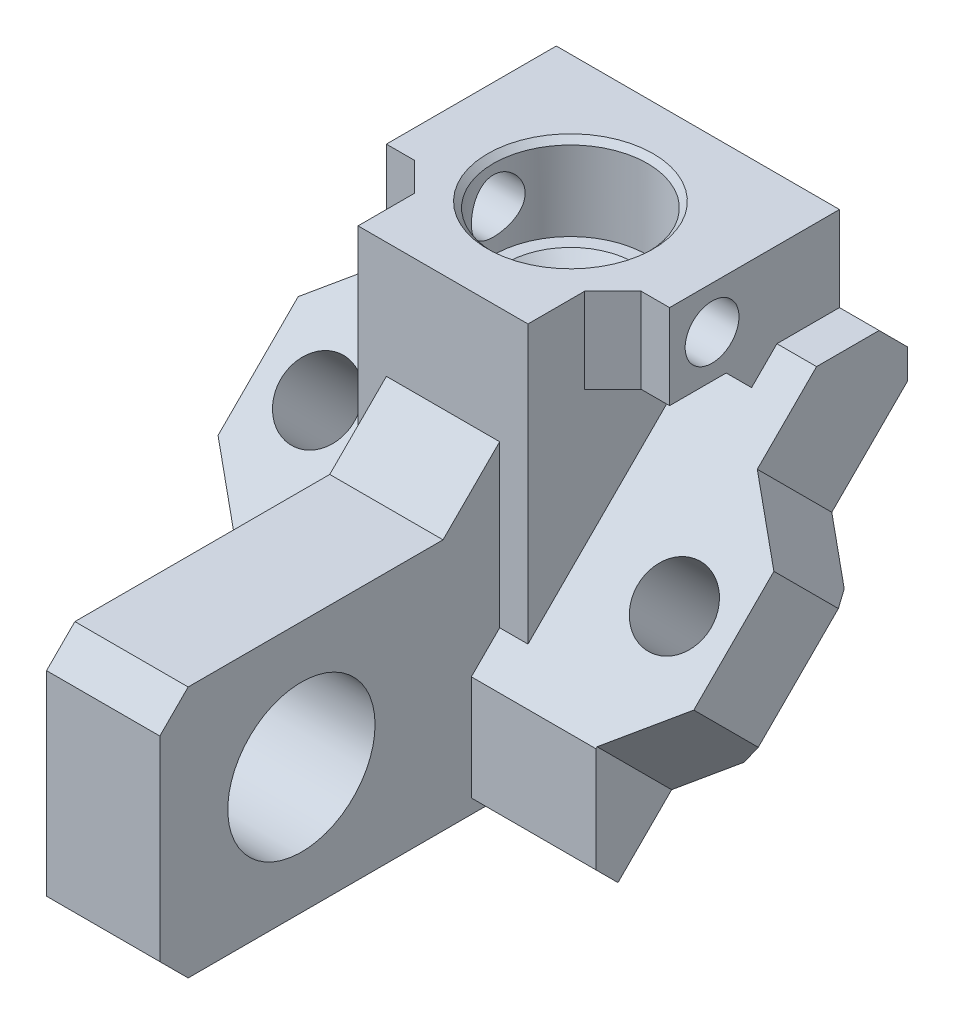
from build123d import *

# Parameters (mm, degrees)
SKETCH2_W                = 4.5
SKETCH2_H                = 5.27595021
BOSS_EXTRUDE1_DEPTH      = 1.5
BOSS_EXTRUDE2_DEPTH      = 3.2
CUT_EXTRUDE1_DEPTH       = 7.4
SKETCH5_R                = 1.3
BOSS_EXTRUDE3_DEPTH      = 1
BOSS_EXTRUDE4_DEPTH      = 1.86
SKETCH7_R                = 0.65
CUT_EXTRUDE2_DEPTH       = 10.564291115
SKETCH8_W                = 4.5
SKETCH8_H                = 5.34
CUT_EXTRUDE3_DEPTH       = 0.7
FILLET1_R                = 0.2
SKETCH9_W                = 1.19
SKETCH9_H                = 1.19
BOSS_EXTRUDE5_DEPTH      = 0.4
FILLET2_R                = 0.5
BOSS_EXTRUDE6_DEPTH      = 2.5
SKETCH10_R               = 0.925
CUT_EXTRUDE4_DEPTH       = 1
CUT_EXTRUDE4_DEPTH_BACK  = 8.63704148
M1_2X0_25_TAPPED_HOLE1_D = 0.95
CHAMFER1_SIZE            = 0.5
SKETCH14_R               = 1.36
CUT_EXTRUDE5_DEPTH       = 1.5
CHAMFER2_SIZE            = 0.2
CHAMFER3_SIZE            = 0.1
CHAMFER4_SIZE            = 0.25


with BuildPart() as part:
    # Sketch2 → Boss-Extrude1 (new body, symmetric)
    with BuildSketch(Plane(origin=(0, 0, 0), x_dir=(0, 0, -1), z_dir=(1, 0, 0))):
        with Locations((0, 2.637975105)):
            Rectangle(SKETCH2_W, SKETCH2_H)
    extrude(amount=BOSS_EXTRUDE1_DEPTH, both=True)

    # Sketch3 → Boss-Extrude2 (add, symmetric)
    with BuildSketch(Plane(origin=(0, 0, 0), x_dir=(0, 0, -1), z_dir=(1, 0, 0))):
        Polygon((0, 0), (2.75, 2.75), (2.75, 3.27595021), (2.25, 3.77595021), (1.145512984, 3.77595021), (-2.75, -0.119562774), (-2.75, -1.972182541), (-2.36109127, -2.36109127), align=None)
    extrude(amount=BOSS_EXTRUDE2_DEPTH, both=True)

    # Sketch4 → Cut-Extrude1 (cut, through all)
    with BuildSketch(Plane(origin=(3.2, 0, 0), x_dir=(0, 0, -1), z_dir=(1, 0, 0))):
        Polygon((2.25, 2.25), (0, 0), (2.25, 0), align=None)
    extrude(amount=-CUT_EXTRUDE1_DEPTH, mode=Mode.SUBTRACT)

    # Sketch5 → Boss-Extrude3 (add, symmetric)
    with BuildSketch(Plane(origin=(0, 0, 0), x_dir=(0, 0, -1), z_dir=(1, 0, 0))):
        Polygon((-2.497182541, -2.225), (-7.75, -2.225), (-8.25, -1.725), (-8.25, 1.725), (-7.75, 2.225), (-3.25, 2.225), (-2.25, 3.225), (-2.25, 0.380437226), (-2.75, -0.119562774), (-2.75, -1.972182541), align=None)
        with Locations((-5.75, 0)):
            Circle(SKETCH5_R, mode=Mode.SUBTRACT)
    extrude(amount=BOSS_EXTRUDE3_DEPTH, both=True)

    # Sketch6 → Boss-Extrude4 (add)
    with BuildSketch(Plane(origin=(0, 0, 0), x_dir=(1, 0, 0), z_dir=(0, -0.707106781, -0.707106781))):
        Polygon((-3.2, 2), (-4.2, 1), (-4.2, -1), (-3.2, -2), align=None)
        Polygon((3.2, -2), (3.2, 2), (4.2, 1), (4.2, -1), align=None)
    extrude(amount=-BOSS_EXTRUDE4_DEPTH)

    # Sketch7 → Cut-Extrude2 (cut, through all)
    with BuildSketch(Plane(origin=(0, 0, 0), x_dir=(1, 0, 0), z_dir=(0, -0.707106781, -0.707106781))):
        with Locations((-3.15, 0)):
            Circle(SKETCH7_R)
        with Locations((3.15, 0)):
            Circle(SKETCH7_R)
    extrude(amount=-CUT_EXTRUDE2_DEPTH, mode=Mode.SUBTRACT)

    # Sketch8 → Cut-Extrude3 (cut)
    with BuildSketch(Plane(origin=(0, 0, 0), x_dir=(1, 0, 0), z_dir=(0, -0.707106781, -0.707106781))):
        with Locations((0, 0.17)):
            Rectangle(SKETCH8_W, SKETCH8_H)
    extrude(amount=-CUT_EXTRUDE3_DEPTH, mode=Mode.SUBTRACT)

    # Fillet1
    fillet1_edges = [part.edges().sort_by_distance(p)[0] for p in [
        (-2.25, 2.015254326, -1.52027958),
        (-2.25, -1.760695885, 2.255670632),
        (2.25, -1.760695885, 2.255670632),
        (2.25, 2.015254326, -1.52027958),
    ]]
    fillet(fillet1_edges, radius=FILLET1_R)

    # Sketch9 → Boss-Extrude5 (add)
    with BuildSketch(Plane(origin=(0, 0.494974747, 0.494974747), x_dir=(1, 0, 0), z_dir=(0, -0.707106781, -0.707106781))):
        with Locations((-1.655, 2.245)):
            Rectangle(SKETCH9_W, SKETCH9_H)
        with Locations((1.655, 2.245)):
            Rectangle(SKETCH9_W, SKETCH9_H)
        with Locations((1.655, -1.905)):
            Rectangle(SKETCH9_W, SKETCH9_H)
        with Locations((-1.655, -1.905)):
            Rectangle(SKETCH9_W, SKETCH9_H)
    extrude(amount=BOSS_EXTRUDE5_DEPTH)

    # Fillet2
    fillet2_edges = [part.edges().sort_by_distance(p)[0] for p in [
        (-1.06, -0.813172798, 1.52027958),
        (1.06, -0.813172798, 1.52027958),
        (1.06, 1.279863274, -0.572756493),
        (-1.06, 1.279863274, -0.572756493),
    ]]
    fillet(fillet2_edges, radius=FILLET2_R)

    # Sketch11 → Boss-Extrude6 (add, symmetric)
    with BuildSketch(Plane(origin=(0, 0, 0), x_dir=(0, 0, -1), z_dir=(1, 0, 0))):
        Polygon((2.25, 5.27595021), (-0.75, 5.27595021), (-0.75, 3.77595021), (0.25, 3.77595021), (0.697756492, 3.328193718), (1.145512984, 3.77595021), (2.25, 3.77595021), align=None)
    extrude(amount=BOSS_EXTRUDE6_DEPTH, both=True)

    # Sketch10 → Cut-Extrude4 (cut, two sides)
    with BuildSketch(Plane(origin=(0, 5.27595021, 0), x_dir=(1, 0, 0), z_dir=(0, 1, 0))) as cut_extrude4_sk:
        Circle(SKETCH10_R)
    extrude(amount=CUT_EXTRUDE4_DEPTH, mode=Mode.SUBTRACT)
    extrude(cut_extrude4_sk.sketch, amount=-CUT_EXTRUDE4_DEPTH_BACK, mode=Mode.SUBTRACT)

    # M1.2x0.25 Tapped Hole1 (through all)
    with Locations(Plane(origin=(2.5, 0, 0), x_dir=(0, 0, -1), z_dir=(1, 0, 0))):
        with Locations((0, 4.52595021)):
            Hole(M1_2X0_25_TAPPED_HOLE1_D / 2)

    # Chamfer1
    chamfer1_edges = [part.edges().sort_by_distance(p)[0] for p in [
        (1.5, 4.52595021, 0.75),
        (-1.5, 4.52595021, 0.75),
    ]]
    chamfer(chamfer1_edges, length=CHAMFER1_SIZE)

    # Sketch14 → Cut-Extrude5 (cut)
    with BuildSketch(Plane(origin=(0, 5.27595021, 0), x_dir=(1, 0, 0), z_dir=(0, 1, 0))):
        Circle(SKETCH14_R)
    extrude(amount=-CUT_EXTRUDE5_DEPTH, mode=Mode.SUBTRACT)

    # Chamfer2
    chamfer2_edges = [part.edges().sort_by_distance(p)[0] for p in [
        (-0.925, 3.77595021, 0),
    ]]
    chamfer(chamfer2_edges, length=CHAMFER2_SIZE)

    # Chamfer3
    chamfer3_edges = [part.edges().sort_by_distance(p)[0] for p in [
        (-1.36, 5.27595021, 0),
    ]]
    chamfer(chamfer3_edges, length=CHAMFER3_SIZE)

    # Chamfer4
    chamfer4_edges = [part.edges().sort_by_distance(p)[0] for p in [
        (4.2, 0, 0),
        (-4.2, 0, 0),
    ]]
    chamfer(chamfer4_edges, length=CHAMFER4_SIZE)


solid = part.part
